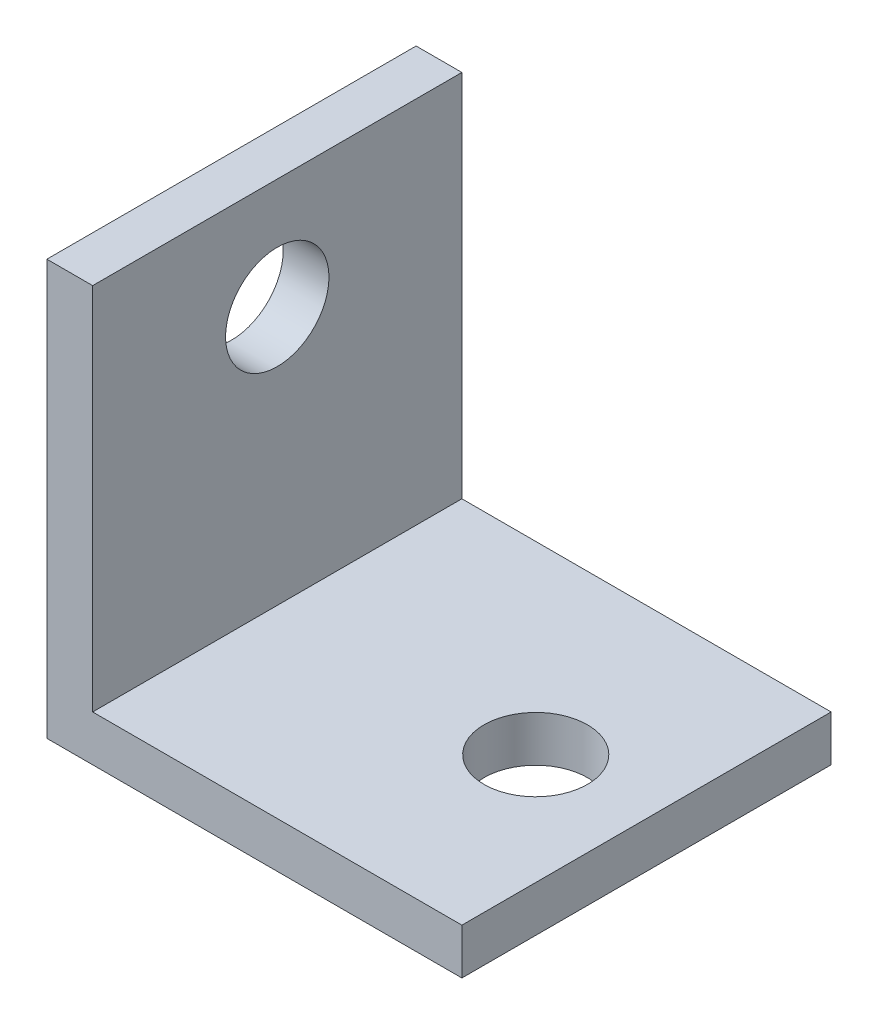
from build123d import *

# Parameters (mm, degrees)
EXTRUDE1_DEPTH     = 12.7
SKETCH2_R          = 1.778
CUT_EXTRUDE1_DEPTH = 7.1374
SKETCH4_R          = 1.778
CUT_EXTRUDE2_DEPTH = 7.1374


with BuildPart() as part:
    # Sketch1 → Extrude1 (new body)
    with BuildSketch(Plane.XY):
        Polygon((0, 0), (-14.2748, 0), (-14.2748, 14.2748), (-12.7, 14.2748), (-12.7, 1.5748), (0, 1.5748), align=None)
    extrude(amount=EXTRUDE1_DEPTH)

    # Sketch2 → Cut-Extrude1 (cut)
    with BuildSketch(Plane(origin=(-12.7, 0, 0), x_dir=(0, 0, -1), z_dir=(1, 0, 0))):
        with Locations((-6.35, 10.4648)):
            Circle(SKETCH2_R)
    extrude(amount=-CUT_EXTRUDE1_DEPTH, mode=Mode.SUBTRACT)

    # Sketch4 → Cut-Extrude2 (cut)
    with BuildSketch(Plane(origin=(0, 1.5748, 0), x_dir=(-1, 0, 0), z_dir=(0, 1, 0))):
        with Locations((3.81, 6.35)):
            Circle(SKETCH4_R)
    extrude(amount=-CUT_EXTRUDE2_DEPTH, mode=Mode.SUBTRACT)


solid = part.part
